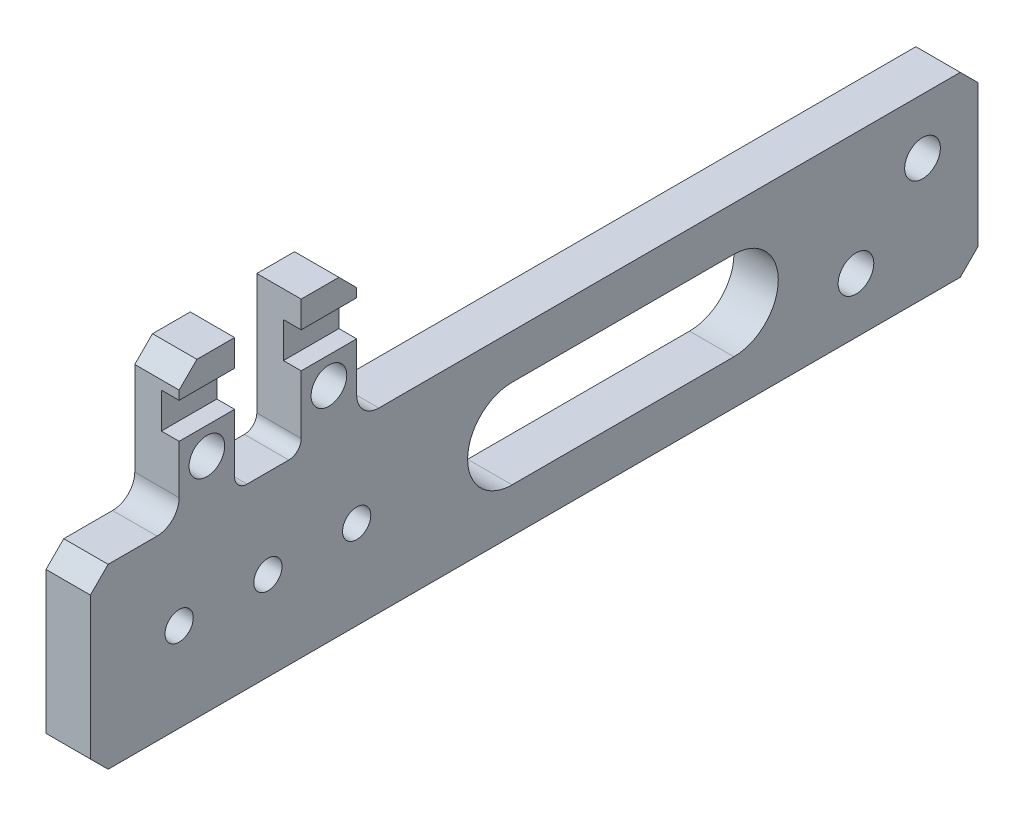
from build123d import *

# Parameters (mm, degrees)
BOSS_EXTRUDE1_DEPTH    = 6.35
F_10_32_TAPPED_HOLE1_D = 4.0386
F_10_CLEARANCE_HOLE1_D = 5.1054
SKETCH6_W              = 25.4
SKETCH6_H              = 5.08
CUT_EXTRUDE1_DEPTH     = 2.54
CHAMFER1_SIZE          = 2.54
CUT_EXTRUDE2_DEPTH     = 7.35


with BuildPart() as part:
    # Sketch1 → Boss-Extrude1 (new body)
    with BuildSketch(Plane(origin=(0, 0, 0), x_dir=(0, 0, -1), z_dir=(1, 0, 0))):
        with BuildLine():
            Line((0, 0), (127, 0))
            Line((127, 0), (127, 25.4))
            Line((127, 25.4), (41.275, 25.4))
            ThreePointArc((41.275, 25.4), (39.02993597, 26.32993597), (38.1, 28.575))
            Line((38.1, 28.575), (38.1, 44.45))
            Line((38.1, 44.45), (30.1625, 44.45))
            Line((30.1625, 44.45), (30.1625, 27.178))
            ThreePointArc((30.1625, 27.178), (29.641735857, 25.920764143), (28.3845, 25.4))
            Line((28.3845, 25.4), (22.4155, 25.4))
            ThreePointArc((22.4155, 25.4), (21.158264143, 25.920764143), (20.6375, 27.178))
            Line((20.6375, 27.178), (20.6375, 44.45))
            Line((20.6375, 44.45), (12.7, 44.45))
            Line((12.7, 44.45), (12.7, 28.575))
            ThreePointArc((12.7, 28.575), (11.77006403, 26.32993597), (9.525, 25.4))
            Line((9.525, 25.4), (0, 25.4))
            Line((0, 25.4), (0, 0))
        make_face()
    extrude(amount=BOSS_EXTRUDE1_DEPTH)

    # #10-32 Tapped Hole1 (through all)
    with Locations(Plane(origin=(6.35, 0, 0), x_dir=(0, 0, -1), z_dir=(1, 0, 0))):
        with Locations((12.7, 12.7), (25.4, 12.7), (38.1, 12.7)):
            Hole(F_10_32_TAPPED_HOLE1_D / 2)

    # #10 Clearance Hole1 (through all)
    with Locations(Plane(origin=(6.35, 0, 0), x_dir=(0, 0, -1), z_dir=(1, 0, 0))):
        with Locations((119.0625, 17.4625), (109.5375, 7.9375), (34.13125, 31.75), (16.66875, 31.75)):
            Hole(F_10_CLEARANCE_HOLE1_D / 2)

    # Sketch6 → Cut-Extrude1 (cut)
    with BuildSketch(Plane(origin=(6.35, 0, 0), x_dir=(0, 0, -1), z_dir=(1, 0, 0))):
        with Locations((25.4, 38.1)):
            Rectangle(SKETCH6_W, SKETCH6_H)
    extrude(amount=-CUT_EXTRUDE1_DEPTH, mode=Mode.SUBTRACT)

    # Chamfer1
    chamfer1_edges = [part.edges().sort_by_distance(p)[0] for p in [
        (3.175, 25.4, 0),
        (3.175, 44.45, -12.7),
        (3.175, 44.45, -38.1),
        (3.175, 25.4, -127),
        (3.175, 0, -127),
        (3.175, 0, 0),
    ]]
    chamfer(chamfer1_edges, length=CHAMFER1_SIZE)

    # Sketch7 → Cut-Extrude2 (cut, through all)
    with BuildSketch(Plane(origin=(6.35, 0, 0), x_dir=(0, 0, -1), z_dir=(1, 0, 0))):
        with BuildLine():
            Line((60.325, 19.05), (92.075, 19.05))
            ThreePointArc((92.075, 19.05), (98.425, 12.7), (92.075, 6.35))
            Line((92.075, 6.35), (60.325, 6.35))
            ThreePointArc((60.325, 6.35), (53.975, 12.7), (60.325, 19.05))
        make_face()
    extrude(amount=-CUT_EXTRUDE2_DEPTH, mode=Mode.SUBTRACT)


solid = part.part
